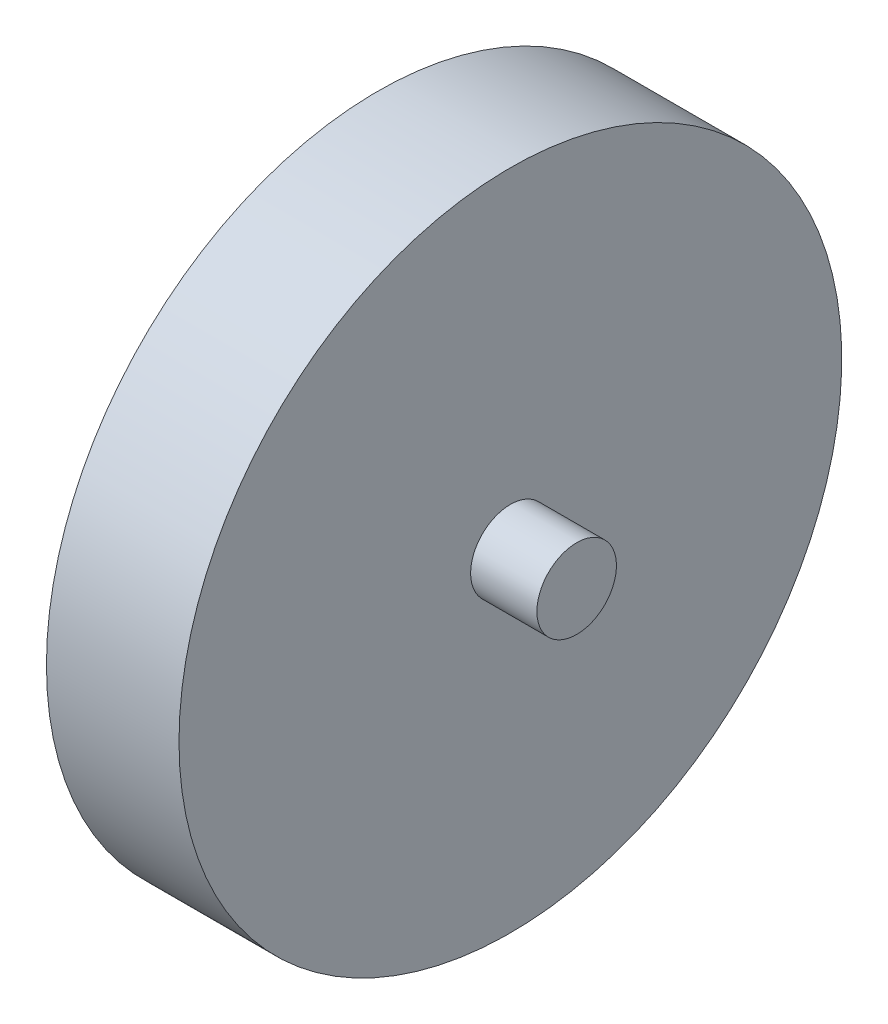
from build123d import *


with BuildPart() as part:
    # Esboço1 → Revolução1 (revolve)
    with BuildSketch(Plane.XY):
        Polygon((0, 0), (0, 50), (20, 50), (20, 6), (30, 6), (30, 0), align=None)
    revolve(axis=Axis((0, 0, 0), (1, 0, 0)))


solid = part.part
